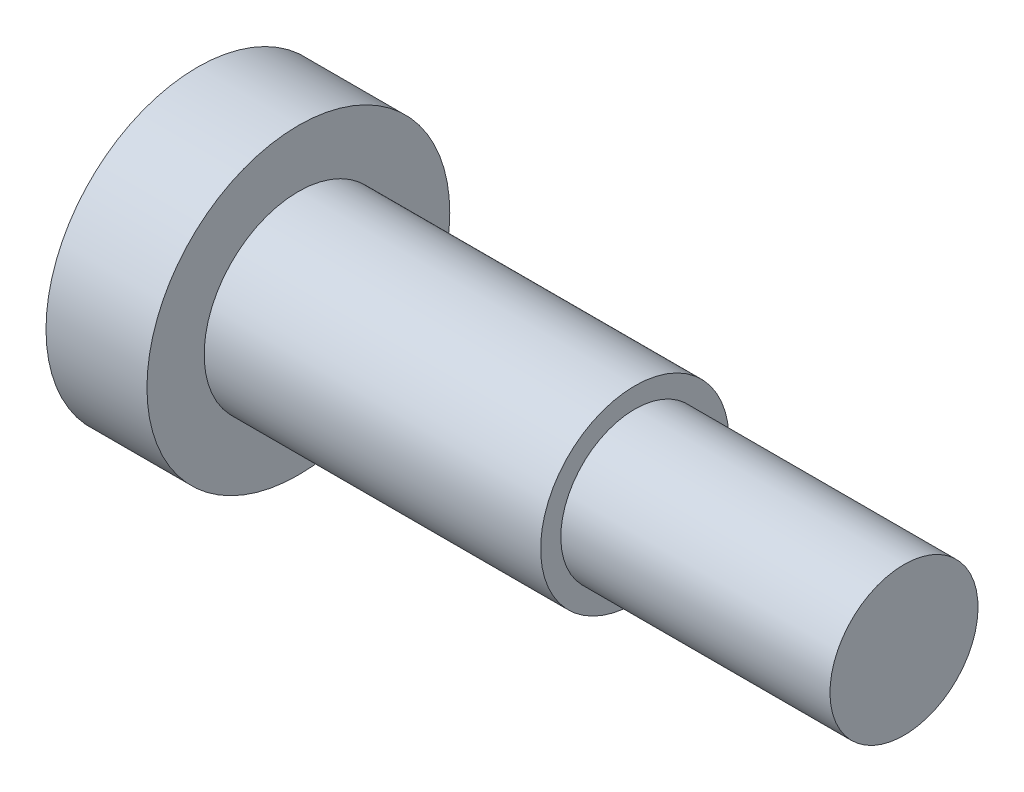
from build123d import *


with BuildPart() as part:
    # Sketch7 → Revolve1 (revolve)
    with BuildSketch(Plane.XY):
        Polygon((0, 0), (0, 22.5), (15, 22.5), (15, 14), (65, 14), (65, 11), (105, 11), (105, 0), align=None)
    revolve(axis=Axis((105, 0, 0), (-1, 0, 0)))


solid = part.part
